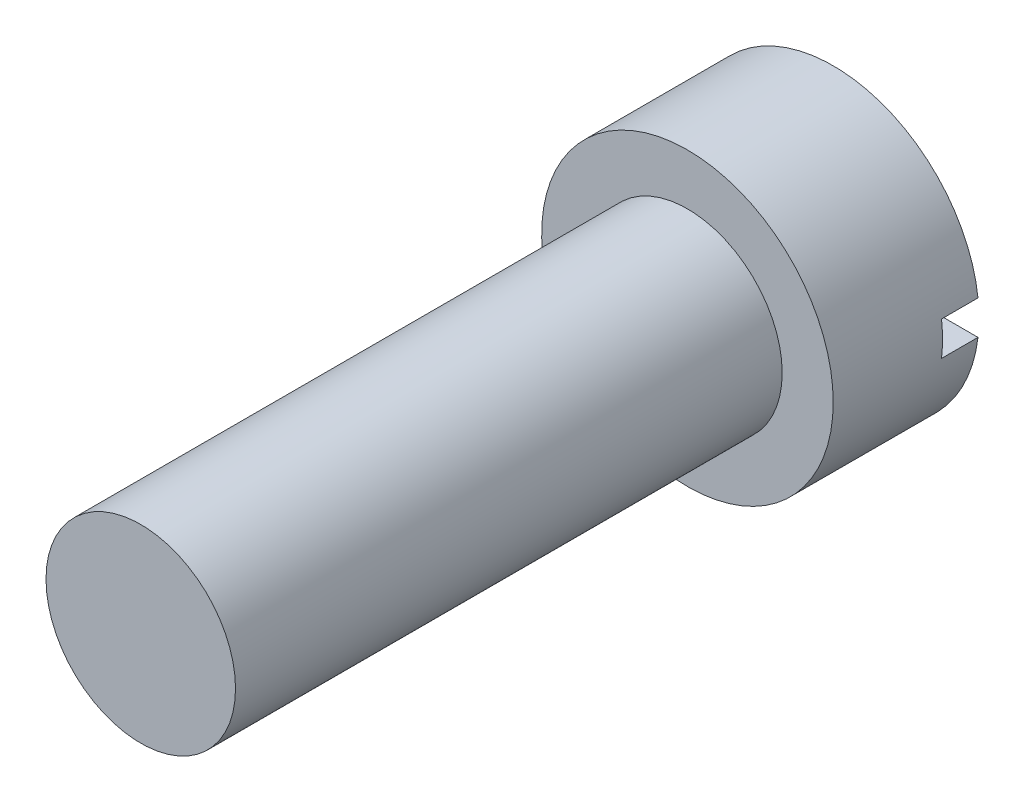
from build123d import *

# Parameters (mm, degrees)
ESQUISSE1_R             = 2
BOSS_EXTRU_1_DEPTH      = 2
ESQUISSE2_R             = 1.3
BOSS_EXTRU_2_DEPTH      = 7.5
ESQUISSE3_W             = 5.055349602
ESQUISSE3_H             = 0.46857679
ENL_V_MAT_EXTRU_1_DEPTH = 0.5


with BuildPart() as part:
    # Esquisse1 → Boss.-Extru.1 (new body)
    with BuildSketch(Plane.XY):
        Circle(ESQUISSE1_R)
    extrude(amount=BOSS_EXTRU_1_DEPTH)

    # Esquisse2 → Boss.-Extru.2 (add)
    with BuildSketch(Plane.XY.offset(2)):
        Circle(ESQUISSE2_R)
    extrude(amount=BOSS_EXTRU_2_DEPTH)

    # Esquisse3 → Enlèv. mat.-Extru.1 (cut)
    with BuildSketch(Plane(origin=(0, 0, 0), x_dir=(-1, 0, 0), z_dir=(0, 0, -1))):
        Rectangle(ESQUISSE3_W, ESQUISSE3_H)
    extrude(amount=-ENL_V_MAT_EXTRU_1_DEPTH, mode=Mode.SUBTRACT)


solid = part.part
